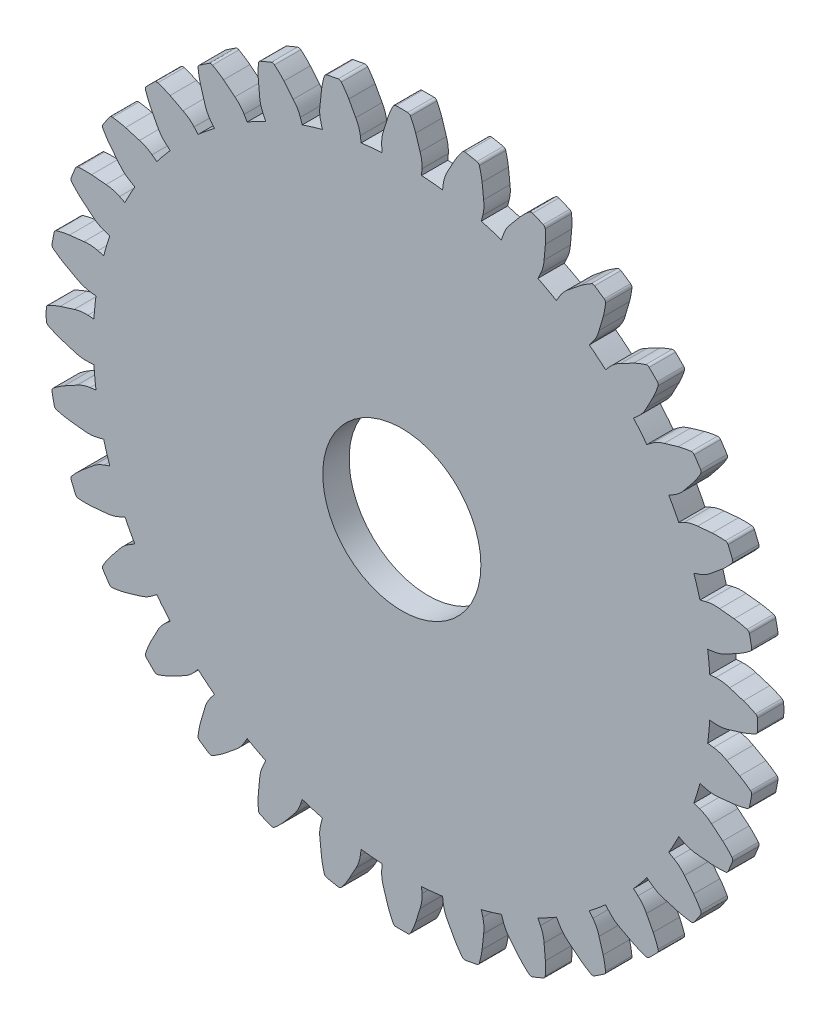
from build123d import *

# Parameters (mm, degrees)
MODEL_R             = 6
BOSS_EXTRUDE1_DEPTH = 2


with BuildPart() as part:
    # Model → Boss-Extrude1 (new body)
    with BuildSketch(Plane.XY):
        with BuildLine():
            Line((51.586845326, 30.54868928), (52.03848659, 30.577630118))
            ThreePointArc((52.03848659, 30.577630118), (52.570679137, 30.558733236), (53.08864278, 30.435041426))
            ThreePointArc((53.08864278, 30.435041426), (53.617059195, 30.27036576), (54.145449742, 30.105607112))
            ThreePointArc((54.145449742, 30.105607112), (54.613471462, 29.924451771), (55.067641968, 29.710931892))
            ThreePointArc((55.067641968, 29.710931892), (55.165460247, 29.620801386), (55.203028673, 29.493206177))
            ThreePointArc((55.203028673, 29.493206177), (55.205742279, 29.272262721), (55.206646834, 29.051304453))
            ThreePointArc((55.206646834, 29.051304453), (55.205742279, 28.830346185), (55.203028673, 28.609402728))
            ThreePointArc((55.203028673, 28.609402728), (55.165460247, 28.48180752), (55.067641968, 28.391677014))
            ThreePointArc((55.067641968, 28.391677014), (54.613471462, 28.178157135), (54.145449742, 27.997001794))
            ThreePointArc((54.145449742, 27.997001794), (53.617059195, 27.832243146), (53.08864278, 27.667567479))
            ThreePointArc((53.08864278, 27.667567479), (52.570679137, 27.54387567), (52.03848659, 27.524978787))
            Line((52.03848659, 27.524978787), (51.586845326, 27.553919625))
            ThreePointArc((51.586845326, 27.553919625), (51.557841022, 27.154768738), (51.522019199, 26.756171851))
            ThreePointArc((51.522019199, 26.756171851), (51.479390321, 26.358245401), (51.42996684, 25.961105627))
            Line((51.42996684, 25.961105627), (51.878576021, 25.901379535))
            ThreePointArc((51.878576021, 25.901379535), (52.396856039, 25.779020136), (52.880736081, 25.556655336))
            ThreePointArc((52.880736081, 25.556655336), (53.366872493, 25.292054937), (53.852967347, 25.027378199))
            ThreePointArc((53.852967347, 25.027378199), (54.276654506, 24.758397199), (54.680442592, 24.460375774))
            ThreePointArc((54.680442592, 24.460375774), (54.758797731, 24.352893701), (54.7707517, 24.220420962))
            ThreePointArc((54.7707517, 24.220420962), (54.730309234, 24.003193474), (54.688089589, 23.786304387))
            ThreePointArc((54.688089589, 23.786304387), (54.644095595, 23.56976824), (54.5983302, 23.353599549))
            ThreePointArc((54.5983302, 23.353599549), (54.536591051, 23.235785283), (54.423068733, 23.166470009))
            ThreePointArc((54.423068733, 23.166470009), (53.935969324, 23.045657125), (53.441598856, 22.959289141))
            ThreePointArc((53.441598856, 22.959289141), (52.891218368, 22.900780166), (52.340828698, 22.842357625))
            ThreePointArc((52.340828698, 22.842357625), (51.808686506, 22.822092213), (51.28303329, 22.907384044))
            Line((51.28303329, 22.907384044), (50.845716264, 23.023879631))
            ThreePointArc((50.845716264, 23.023879631), (50.739398794, 22.638056775), (50.626502883, 22.254107307))
            ThreePointArc((50.626502883, 22.254107307), (50.507061507, 21.872143384), (50.381109558, 21.492276582))
            Line((50.381109558, 21.492276582), (50.809446857, 21.346178801))
            ThreePointArc((50.809446857, 21.346178801), (51.293897135, 21.125059087), (51.725098337, 20.812566651))
            ThreePointArc((51.725098337, 20.812566651), (52.150272798, 20.458209966), (52.575391605, 20.103786515))
            ThreePointArc((52.575391605, 20.103786515), (52.938462145, 19.757316645), (53.27635046, 19.386246471))
            ThreePointArc((53.27635046, 19.386246471), (53.332231314, 19.265543306), (53.318111442, 19.13328389))
            ThreePointArc((53.318111442, 19.13328389), (53.236067086, 18.928120302), (53.152345718, 18.723635322))
            ThreePointArc((53.152345718, 18.723635322), (53.066952949, 18.519842659), (52.979894504, 18.316755974))
            ThreePointArc((52.979894504, 18.316755974), (52.896357232, 18.213250186), (52.771493475, 18.167413891))
            ThreePointArc((52.771493475, 18.167413891), (52.270184119, 18.143950773), (51.768463284, 18.15568922))
            ThreePointArc((51.768463284, 18.15568922), (51.217243668, 18.205678385), (50.666031908, 18.255754115))
            ThreePointArc((50.666031908, 18.255754115), (50.140161094, 18.339693888), (49.641247768, 18.525896716))
            Line((49.641247768, 18.525896716), (49.235060827, 18.725470193))
            ThreePointArc((49.235060827, 18.725470193), (49.055515913, 18.367802324), (48.869884439, 18.013255237))
            ThreePointArc((48.869884439, 18.013255237), (48.678220632, 17.6619325), (48.480580477, 17.313936738))
            Line((48.480580477, 17.313936738), (48.872185132, 17.087081723))
            ThreePointArc((48.872185132, 17.087081723), (49.304188517, 16.775699202), (49.666140059, 16.38508804))
            ThreePointArc((49.666140059, 16.38508804), (50.014013352, 15.954592796), (50.361819035, 15.524042928))
            ThreePointArc((50.361819035, 15.524042928), (50.650320358, 15.113398831), (50.909324044, 14.683539926))
            ThreePointArc((50.909324044, 14.683539926), (50.940583144, 14.554254225), (50.900932049, 14.427290787))
            ThreePointArc((50.900932049, 14.427290787), (50.780438722, 14.242075419), (50.658432996, 14.057852789))
            ThreePointArc((50.658432996, 14.057852789), (50.534923049, 13.874635248), (50.409917161, 13.692435076))
            ThreePointArc((50.409917161, 13.692435076), (50.307792057, 13.607215437), (50.176385304, 13.586619584))
            ThreePointArc((50.176385304, 13.586619584), (49.68013104, 13.661407907), (49.190340687, 13.770801682))
            ThreePointArc((49.190340687, 13.770801682), (48.659465004, 13.927367932), (48.128613914, 14.08401755))
            ThreePointArc((48.128613914, 14.08401755), (47.629223397, 14.268936751), (47.176222921, 14.548894905))
            Line((47.176222921, 14.548894905), (46.816775602, 14.823876774))
            ThreePointArc((46.816775602, 14.823876774), (46.570903053, 14.508108868), (46.319669731, 14.196589208))
            ThreePointArc((46.319669731, 14.196589208), (46.063149024, 13.889408793), (45.801415864, 13.586657354))
            Line((45.801415864, 13.586657354), (46.141238727, 13.287763016))
            ThreePointArc((46.141238727, 13.287763016), (46.504193572, 12.898083943), (46.78298586, 12.444365022))
            ThreePointArc((46.78298586, 12.444365022), (47.040189409, 11.954274911), (47.297315991, 11.464144415))
            ThreePointArc((47.297315991, 11.464144415), (47.500161153, 11.005106913), (47.670326843, 10.532978514))
            ThreePointArc((47.670326843, 10.532978514), (47.675762919, 10.400078653), (47.612104371, 10.283290327))
            ThreePointArc((47.612104371, 10.283290327), (47.457792564, 10.125140902), (47.302191091, 9.968260195))
            ThreePointArc((47.302191091, 9.968260195), (47.145310384, 9.812658723), (46.987160959, 9.658346916))
            ThreePointArc((46.987160959, 9.658346916), (46.870372633, 9.594688367), (46.737472773, 9.600124443))
            ThreePointArc((46.737472773, 9.600124443), (46.265344374, 9.770290134), (45.806306872, 9.973135296))
            ThreePointArc((45.806306872, 9.973135296), (45.316176376, 10.230261878), (44.826086265, 10.487465427))
            ThreePointArc((44.826086265, 10.487465427), (44.372367343, 10.766257714), (43.982688271, 11.129212559))
            Line((43.982688271, 11.129212559), (43.683793933, 11.469035423))
            ThreePointArc((43.683793933, 11.469035423), (43.381042494, 11.207302263), (43.073862078, 10.950781556))
            ThreePointArc((43.073862078, 10.950781556), (42.762342418, 10.699548234), (42.446574512, 10.453675685))
            Line((42.446574512, 10.453675685), (42.721556382, 10.094228366))
            ThreePointArc((42.721556382, 10.094228366), (43.001514536, 9.64122789), (43.186433737, 9.141837373))
            ThreePointArc((43.186433737, 9.141837373), (43.343083355, 8.610986283), (43.499649605, 8.080110599))
            ThreePointArc((43.499649605, 8.080110599), (43.60904338, 7.590320246), (43.683831703, 7.094065983))
            ThreePointArc((43.683831703, 7.094065983), (43.66323585, 6.96265923), (43.578016211, 6.860534125))
            ThreePointArc((43.578016211, 6.860534125), (43.395816039, 6.735528238), (43.212598498, 6.612018291))
            ThreePointArc((43.212598498, 6.612018291), (43.028375868, 6.490012565), (42.8431605, 6.369519238))
            ThreePointArc((42.8431605, 6.369519238), (42.716197062, 6.329868142), (42.586911361, 6.361127242))
            ThreePointArc((42.586911361, 6.361127242), (42.157052456, 6.620130929), (41.746408359, 6.908632251))
            ThreePointArc((41.746408359, 6.908632251), (41.31585849, 7.256437934), (40.885363247, 7.604311227))
            ThreePointArc((40.885363247, 7.604311227), (40.494752084, 7.966262769), (40.183369563, 8.398266155))
            Line((40.183369563, 8.398266155), (39.956514548, 8.78987081))
            ThreePointArc((39.956514548, 8.78987081), (39.608518787, 8.592230655), (39.25719605, 8.400566847))
            ThreePointArc((39.25719605, 8.400566847), (38.902648963, 8.214935374), (38.544981094, 8.035390459))
            Line((38.544981094, 8.035390459), (38.744554571, 7.629203519))
            ThreePointArc((38.744554571, 7.629203519), (38.930757398, 7.130290193), (39.014697172, 6.604419378))
            ThreePointArc((39.014697172, 6.604419378), (39.064772901, 6.053207619), (39.114762067, 5.501988003))
            ThreePointArc((39.114762067, 5.501988003), (39.126500513, 5.000267167), (39.103037396, 4.498957812))
            ThreePointArc((39.103037396, 4.498957812), (39.057201101, 4.374094055), (38.953695313, 4.290556782))
            ThreePointArc((38.953695313, 4.290556782), (38.750608628, 4.203498338), (38.546815965, 4.118105569))
            ThreePointArc((38.546815965, 4.118105569), (38.342330985, 4.034384201), (38.137167396, 3.952339845))
            ThreePointArc((38.137167396, 3.952339845), (38.004907981, 3.938219973), (37.884204816, 3.994100827))
            ThreePointArc((37.884204816, 3.994100827), (37.513134641, 4.331989142), (37.166664772, 4.695059682))
            ThreePointArc((37.166664772, 4.695059682), (36.812241321, 5.120178489), (36.457884636, 5.545352949))
            ThreePointArc((36.457884636, 5.545352949), (36.1453922, 5.976554152), (35.924272486, 6.461004429))
            Line((35.924272486, 6.461004429), (35.778174705, 6.889341729))
            ThreePointArc((35.778174705, 6.889341729), (35.398307903, 6.763389779), (35.01634398, 6.643948404))
            ThreePointArc((35.01634398, 6.643948404), (34.632394512, 6.531052492), (34.246571656, 6.424735023))
            Line((34.246571656, 6.424735023), (34.363067243, 5.987417997))
            ThreePointArc((34.363067243, 5.987417997), (34.448359074, 5.461764781), (34.428093662, 4.929622589))
            ThreePointArc((34.428093662, 4.929622589), (34.369671121, 4.379232919), (34.311162146, 3.828852431))
            ThreePointArc((34.311162146, 3.828852431), (34.224794162, 3.334481963), (34.103981278, 2.847382554))
            ThreePointArc((34.103981278, 2.847382554), (34.034666004, 2.733860236), (33.916851738, 2.672121086))
            ThreePointArc((33.916851738, 2.672121086), (33.700683046, 2.626355692), (33.484146899, 2.582361698))
            ThreePointArc((33.484146899, 2.582361698), (33.267257812, 2.540142053), (33.050030325, 2.499699587))
            ThreePointArc((33.050030325, 2.499699587), (32.917557586, 2.511653556), (32.810075513, 2.590008695))
            ThreePointArc((32.810075513, 2.590008695), (32.512054088, 2.99379678), (32.243073088, 3.41748394))
            ThreePointArc((32.243073088, 3.41748394), (31.978396349, 3.903578793), (31.713795951, 4.389715206))
            ThreePointArc((31.713795951, 4.389715206), (31.491431151, 4.873595248), (31.369071751, 5.391875265))
            Line((31.369071751, 5.391875265), (31.30934566, 5.840484447))
            ThreePointArc((31.30934566, 5.840484447), (30.912205885, 5.791060966), (30.514279435, 5.748432087))
            ThreePointArc((30.514279435, 5.748432087), (30.115682549, 5.712610264), (29.716531662, 5.683605961))
            Line((29.716531662, 5.683605961), (29.7454725, 5.231964697))
            ThreePointArc((29.7454725, 5.231964697), (29.726575617, 4.699772149), (29.602883807, 4.181808506))
            ThreePointArc((29.602883807, 4.181808506), (29.438208141, 3.653392092), (29.273449493, 3.125001545))
            ThreePointArc((29.273449493, 3.125001545), (29.092294152, 2.656979825), (28.878774273, 2.202809318))
            ThreePointArc((28.878774273, 2.202809318), (28.788643767, 2.10499104), (28.661048558, 2.067422613))
            ThreePointArc((28.661048558, 2.067422613), (28.440105102, 2.064709008), (28.219146834, 2.063804453))
            ThreePointArc((28.219146834, 2.063804453), (27.998188566, 2.064709008), (27.77724511, 2.067422613))
            ThreePointArc((27.77724511, 2.067422613), (27.649649901, 2.10499104), (27.559519395, 2.202809318))
            ThreePointArc((27.559519395, 2.202809318), (27.345999516, 2.656979825), (27.164844175, 3.125001545))
            ThreePointArc((27.164844175, 3.125001545), (27.000085527, 3.653392092), (26.835409861, 4.181808506))
            ThreePointArc((26.835409861, 4.181808506), (26.711718051, 4.699772149), (26.692821168, 5.231964697))
            Line((26.692821168, 5.231964697), (26.721762006, 5.683605961))
            ThreePointArc((26.721762006, 5.683605961), (26.322611119, 5.712610264), (25.924014232, 5.748432087))
            ThreePointArc((25.924014232, 5.748432087), (25.526087783, 5.791060966), (25.128948008, 5.840484447))
            Line((25.128948008, 5.840484447), (25.069221917, 5.391875265))
            ThreePointArc((25.069221917, 5.391875265), (24.946862517, 4.873595248), (24.724497717, 4.389715206))
            ThreePointArc((24.724497717, 4.389715206), (24.459897319, 3.903578793), (24.19522058, 3.41748394))
            ThreePointArc((24.19522058, 3.41748394), (23.92623958, 2.99379678), (23.628218155, 2.590008695))
            ThreePointArc((23.628218155, 2.590008695), (23.520736082, 2.511653556), (23.388263343, 2.499699587))
            ThreePointArc((23.388263343, 2.499699587), (23.171035856, 2.540142053), (22.954146769, 2.582361698))
            ThreePointArc((22.954146769, 2.582361698), (22.737610622, 2.626355692), (22.52144193, 2.672121086))
            ThreePointArc((22.52144193, 2.672121086), (22.403627664, 2.733860236), (22.33431239, 2.847382554))
            ThreePointArc((22.33431239, 2.847382554), (22.213499506, 3.334481963), (22.127131522, 3.828852431))
            ThreePointArc((22.127131522, 3.828852431), (22.068622547, 4.379232919), (22.010200006, 4.929622589))
            ThreePointArc((22.010200006, 4.929622589), (21.989934594, 5.461764781), (22.075226425, 5.987417997))
            Line((22.075226425, 5.987417997), (22.191722012, 6.424735023))
            ThreePointArc((22.191722012, 6.424735023), (21.805899156, 6.531052492), (21.421949688, 6.643948404))
            ThreePointArc((21.421949688, 6.643948404), (21.039985765, 6.763389779), (20.660118963, 6.889341729))
            Line((20.660118963, 6.889341729), (20.514021182, 6.461004429))
            ThreePointArc((20.514021182, 6.461004429), (20.292901468, 5.976554152), (19.980409032, 5.545352949))
            ThreePointArc((19.980409032, 5.545352949), (19.626052347, 5.120178489), (19.271628896, 4.695059682))
            ThreePointArc((19.271628896, 4.695059682), (18.925159026, 4.331989142), (18.554088852, 3.994100827))
            ThreePointArc((18.554088852, 3.994100827), (18.433385687, 3.938219973), (18.301126272, 3.952339845))
            ThreePointArc((18.301126272, 3.952339845), (18.095962683, 4.034384201), (17.891477703, 4.118105569))
            ThreePointArc((17.891477703, 4.118105569), (17.68768504, 4.203498338), (17.484598355, 4.290556782))
            ThreePointArc((17.484598355, 4.290556782), (17.381092567, 4.374094055), (17.335256272, 4.498957812))
            ThreePointArc((17.335256272, 4.498957812), (17.311793154, 5.000267167), (17.323531601, 5.501988003))
            ThreePointArc((17.323531601, 5.501988003), (17.373520767, 6.053207619), (17.423596496, 6.604419378))
            ThreePointArc((17.423596496, 6.604419378), (17.50753627, 7.130290193), (17.693739097, 7.629203519))
            Line((17.693739097, 7.629203519), (17.893312574, 8.035390459))
            ThreePointArc((17.893312574, 8.035390459), (17.535644705, 8.214935374), (17.181097618, 8.400566847))
            ThreePointArc((17.181097618, 8.400566847), (16.829774881, 8.592230655), (16.48177912, 8.78987081))
            Line((16.48177912, 8.78987081), (16.254924105, 8.398266155))
            ThreePointArc((16.254924105, 8.398266155), (15.943541583, 7.966262769), (15.552930421, 7.604311227))
            ThreePointArc((15.552930421, 7.604311227), (15.122435178, 7.256437934), (14.691885309, 6.908632251))
            ThreePointArc((14.691885309, 6.908632251), (14.281241212, 6.620130929), (13.851382307, 6.361127242))
            ThreePointArc((13.851382307, 6.361127242), (13.722096606, 6.329868142), (13.595133168, 6.369519238))
            ThreePointArc((13.595133168, 6.369519238), (13.4099178, 6.490012565), (13.22569517, 6.612018291))
            ThreePointArc((13.22569517, 6.612018291), (13.042477629, 6.735528238), (12.860277457, 6.860534125))
            ThreePointArc((12.860277457, 6.860534125), (12.775057818, 6.96265923), (12.754461965, 7.094065983))
            ThreePointArc((12.754461965, 7.094065983), (12.829250288, 7.590320246), (12.938644063, 8.080110599))
            ThreePointArc((12.938644063, 8.080110599), (13.095210313, 8.610986283), (13.251859931, 9.141837373))
            ThreePointArc((13.251859931, 9.141837373), (13.436779132, 9.64122789), (13.716737286, 10.094228366))
            Line((13.716737286, 10.094228366), (13.991719155, 10.453675685))
            ThreePointArc((13.991719155, 10.453675685), (13.675951249, 10.699548234), (13.364431589, 10.950781556))
            ThreePointArc((13.364431589, 10.950781556), (13.057251174, 11.207302263), (12.754499735, 11.469035423))
            Line((12.754499735, 11.469035423), (12.455605397, 11.129212559))
            ThreePointArc((12.455605397, 11.129212559), (12.065926325, 10.766257714), (11.612207403, 10.487465427))
            ThreePointArc((11.612207403, 10.487465427), (11.122117292, 10.230261878), (10.631986796, 9.973135296))
            ThreePointArc((10.631986796, 9.973135296), (10.172949294, 9.770290134), (9.700820895, 9.600124443))
            ThreePointArc((9.700820895, 9.600124443), (9.567921035, 9.594688367), (9.451132709, 9.658346916))
            ThreePointArc((9.451132709, 9.658346916), (9.292983284, 9.812658723), (9.136102577, 9.968260195))
            ThreePointArc((9.136102577, 9.968260195), (8.980501104, 10.125140902), (8.826189297, 10.283290327))
            ThreePointArc((8.826189297, 10.283290327), (8.762530748, 10.400078653), (8.767966825, 10.532978514))
            ThreePointArc((8.767966825, 10.532978514), (8.938132515, 11.005106913), (9.140977677, 11.464144415))
            ThreePointArc((9.140977677, 11.464144415), (9.398104259, 11.954274911), (9.655307808, 12.444365022))
            ThreePointArc((9.655307808, 12.444365022), (9.934100095, 12.898083943), (10.29705494, 13.287763016))
            Line((10.29705494, 13.287763016), (10.636877804, 13.586657354))
            ThreePointArc((10.636877804, 13.586657354), (10.375144644, 13.889408793), (10.118623937, 14.196589208))
            ThreePointArc((10.118623937, 14.196589208), (9.867390615, 14.508108868), (9.621518066, 14.823876774))
            Line((9.621518066, 14.823876774), (9.262070747, 14.548894905))
            ThreePointArc((9.262070747, 14.548894905), (8.809070271, 14.268936751), (8.309679754, 14.08401755))
            ThreePointArc((8.309679754, 14.08401755), (7.778828664, 13.927367932), (7.247952981, 13.770801682))
            ThreePointArc((7.247952981, 13.770801682), (6.758162628, 13.661407907), (6.261908364, 13.586619584))
            ThreePointArc((6.261908364, 13.586619584), (6.130501611, 13.607215437), (6.028376507, 13.692435076))
            ThreePointArc((6.028376507, 13.692435076), (5.903370619, 13.874635248), (5.779860672, 14.057852789))
            ThreePointArc((5.779860672, 14.057852789), (5.657854946, 14.242075419), (5.537361619, 14.427290787))
            ThreePointArc((5.537361619, 14.427290787), (5.497710524, 14.554254225), (5.528969624, 14.683539926))
            ThreePointArc((5.528969624, 14.683539926), (5.78797331, 15.113398831), (6.076474633, 15.524042928))
            ThreePointArc((6.076474633, 15.524042928), (6.424280316, 15.954592796), (6.772153608, 16.385088039))
            ThreePointArc((6.772153608, 16.385088039), (7.134105151, 16.775699202), (7.566108536, 17.087081723))
            Line((7.566108536, 17.087081723), (7.957713191, 17.313936738))
            ThreePointArc((7.957713191, 17.313936738), (7.760073036, 17.6619325), (7.568409228, 18.013255237))
            ThreePointArc((7.568409228, 18.013255237), (7.382777755, 18.367802324), (7.203232841, 18.725470193))
            Line((7.203232841, 18.725470193), (6.7970459, 18.525896716))
            ThreePointArc((6.7970459, 18.525896716), (6.298132574, 18.339693888), (5.77226176, 18.255754115))
            ThreePointArc((5.77226176, 18.255754115), (5.22105, 18.205678385), (4.669830384, 18.15568922))
            ThreePointArc((4.669830384, 18.15568922), (4.168109549, 18.143950773), (3.666800193, 18.167413891))
            ThreePointArc((3.666800193, 18.167413891), (3.541936436, 18.213250186), (3.458399164, 18.316755974))
            ThreePointArc((3.458399164, 18.316755974), (3.371340719, 18.519842659), (3.28594795, 18.723635322))
            ThreePointArc((3.28594795, 18.723635322), (3.202226582, 18.928120302), (3.120182226, 19.13328389))
            ThreePointArc((3.120182226, 19.13328389), (3.106062354, 19.265543306), (3.161943208, 19.386246471))
            ThreePointArc((3.161943208, 19.386246471), (3.499831523, 19.757316645), (3.862902063, 20.103786515))
            ThreePointArc((3.862902063, 20.103786515), (4.28802087, 20.458209966), (4.713195331, 20.812566651))
            ThreePointArc((4.713195331, 20.812566651), (5.144396533, 21.125059087), (5.628846811, 21.346178801))
            Line((5.628846811, 21.346178801), (6.05718411, 21.492276582))
            ThreePointArc((6.05718411, 21.492276582), (5.931232161, 21.872143384), (5.811790785, 22.254107307))
            ThreePointArc((5.811790785, 22.254107307), (5.698894874, 22.638056775), (5.592577404, 23.023879631))
            Line((5.592577404, 23.023879631), (5.155260378, 22.907384044))
            ThreePointArc((5.155260378, 22.907384044), (4.629607162, 22.822092213), (4.09746497, 22.842357625))
            ThreePointArc((4.09746497, 22.842357625), (3.5470753, 22.900780166), (2.996694812, 22.959289141))
            ThreePointArc((2.996694812, 22.959289141), (2.502324344, 23.045657125), (2.015224935, 23.166470009))
            ThreePointArc((2.015224935, 23.166470009), (1.901702617, 23.235785283), (1.839963468, 23.353599549))
            ThreePointArc((1.839963468, 23.353599549), (1.794198073, 23.56976824), (1.750204079, 23.786304387))
            ThreePointArc((1.750204079, 23.786304387), (1.707984434, 24.003193474), (1.667541968, 24.220420962))
            ThreePointArc((1.667541968, 24.220420962), (1.679495937, 24.352893701), (1.757851076, 24.460375774))
            ThreePointArc((1.757851076, 24.460375774), (2.161639161, 24.758397199), (2.585326321, 25.027378199))
            ThreePointArc((2.585326321, 25.027378199), (3.071421174, 25.292054937), (3.557557587, 25.556655336))
            ThreePointArc((3.557557587, 25.556655336), (4.041437629, 25.779020136), (4.559717647, 25.901379535))
            Line((4.559717647, 25.901379535), (5.008326828, 25.961105627))
            ThreePointArc((5.008326828, 25.961105627), (4.958903347, 26.358245401), (4.916274468, 26.756171851))
            ThreePointArc((4.916274468, 26.756171851), (4.880452646, 27.154768738), (4.851448342, 27.553919625))
            Line((4.851448342, 27.553919625), (4.399807078, 27.524978787))
            ThreePointArc((4.399807078, 27.524978787), (3.867614531, 27.54387567), (3.349650887, 27.667567479))
            ThreePointArc((3.349650887, 27.667567479), (2.821234473, 27.832243146), (2.292843926, 27.997001794))
            ThreePointArc((2.292843926, 27.997001794), (1.824822206, 28.178157135), (1.3706517, 28.391677014))
            ThreePointArc((1.3706517, 28.391677014), (1.272833421, 28.48180752), (1.235264995, 28.609402728))
            ThreePointArc((1.235264995, 28.609402728), (1.232551389, 28.830346185), (1.231646834, 29.051304453))
            ThreePointArc((1.231646834, 29.051304453), (1.232551389, 29.272262721), (1.235264995, 29.493206177))
            ThreePointArc((1.235264995, 29.493206177), (1.272833421, 29.620801386), (1.3706517, 29.710931892))
            ThreePointArc((1.3706517, 29.710931892), (1.824822206, 29.924451771), (2.292843926, 30.105607112))
            ThreePointArc((2.292843926, 30.105607112), (2.821234473, 30.27036576), (3.349650887, 30.435041426))
            ThreePointArc((3.349650887, 30.435041426), (3.867614531, 30.558733236), (4.399807078, 30.577630118))
            Line((4.399807078, 30.577630118), (4.851448342, 30.54868928))
            ThreePointArc((4.851448342, 30.54868928), (4.880452646, 30.947840168), (4.916274468, 31.346437054))
            ThreePointArc((4.916274468, 31.346437054), (4.958903347, 31.744363504), (5.008326828, 32.141503278))
            Line((5.008326828, 32.141503278), (4.559717647, 32.20122937))
            ThreePointArc((4.559717647, 32.20122937), (4.041437629, 32.32358877), (3.557557587, 32.54595357))
            ThreePointArc((3.557557587, 32.54595357), (3.071421174, 32.810553968), (2.585326321, 33.075230707))
            ThreePointArc((2.585326321, 33.075230707), (2.161639161, 33.344211707), (1.757851076, 33.642233131))
            ThreePointArc((1.757851076, 33.642233131), (1.679495937, 33.749715205), (1.667541968, 33.882187943))
            ThreePointArc((1.667541968, 33.882187943), (1.707984434, 34.099415431), (1.750204079, 34.316304518))
            ThreePointArc((1.750204079, 34.316304518), (1.794198073, 34.532840665), (1.839963468, 34.749009357))
            ThreePointArc((1.839963468, 34.749009357), (1.901702617, 34.866823623), (2.015224935, 34.936138897))
            ThreePointArc((2.015224935, 34.936138897), (2.502324344, 35.056951781), (2.996694812, 35.143319765))
            ThreePointArc((2.996694812, 35.143319765), (3.5470753, 35.201828739), (4.09746497, 35.260251281))
            ThreePointArc((4.09746497, 35.260251281), (4.629607162, 35.280516693), (5.155260378, 35.195224862))
            Line((5.155260378, 35.195224862), (5.592577404, 35.078729274))
            ThreePointArc((5.592577404, 35.078729274), (5.698894874, 35.464552131), (5.811790785, 35.848501599))
            ThreePointArc((5.811790785, 35.848501599), (5.931232161, 36.230465522), (6.05718411, 36.610332324))
            Line((6.05718411, 36.610332324), (5.628846811, 36.756430105))
            ThreePointArc((5.628846811, 36.756430105), (5.144396533, 36.977549819), (4.713195331, 37.290042255))
            ThreePointArc((4.713195331, 37.290042255), (4.28802087, 37.64439894), (3.862902063, 37.99882239))
            ThreePointArc((3.862902063, 37.99882239), (3.499831523, 38.34529226), (3.161943208, 38.716362435))
            ThreePointArc((3.161943208, 38.716362435), (3.106062354, 38.837065599), (3.120182226, 38.969325015))
            ThreePointArc((3.120182226, 38.969325015), (3.202226582, 39.174488604), (3.28594795, 39.378973584))
            ThreePointArc((3.28594795, 39.378973584), (3.371340719, 39.582766247), (3.458399164, 39.785852932))
            ThreePointArc((3.458399164, 39.785852932), (3.541936436, 39.889358719), (3.666800193, 39.935195015))
            ThreePointArc((3.666800193, 39.935195015), (4.168109549, 39.958658132), (4.669830384, 39.946919686))
            ThreePointArc((4.669830384, 39.946919686), (5.22105, 39.89693052), (5.77226176, 39.846854791))
            ThreePointArc((5.77226176, 39.846854791), (6.298132574, 39.762915017), (6.7970459, 39.57671219))
            Line((6.7970459, 39.57671219), (7.203232841, 39.377138713))
            ThreePointArc((7.203232841, 39.377138713), (7.382777755, 39.734806582), (7.568409228, 40.089353669))
            ThreePointArc((7.568409228, 40.089353669), (7.760073036, 40.440676406), (7.957713191, 40.788672167))
            Line((7.957713191, 40.788672167), (7.566108536, 41.015527182))
            ThreePointArc((7.566108536, 41.015527182), (7.134105151, 41.326909703), (6.772153608, 41.717520866))
            ThreePointArc((6.772153608, 41.717520866), (6.424280316, 42.148016109), (6.076474633, 42.578565977))
            ThreePointArc((6.076474633, 42.578565977), (5.78797331, 42.989210075), (5.528969624, 43.41906898))
            ThreePointArc((5.528969624, 43.41906898), (5.497710524, 43.548354681), (5.537361619, 43.675318119))
            ThreePointArc((5.537361619, 43.675318119), (5.657854946, 43.860533487), (5.779860672, 44.044756116))
            ThreePointArc((5.779860672, 44.044756116), (5.903370619, 44.227973658), (6.028376507, 44.410173829))
            ThreePointArc((6.028376507, 44.410173829), (6.130501611, 44.495393469), (6.261908364, 44.515989322))
            ThreePointArc((6.261908364, 44.515989322), (6.758162628, 44.441200999), (7.247952981, 44.331807224))
            ThreePointArc((7.247952981, 44.331807224), (7.778828664, 44.175240974), (8.309679754, 44.018591356))
            ThreePointArc((8.309679754, 44.018591356), (8.809070271, 43.833672155), (9.262070747, 43.553714001))
            Line((9.262070747, 43.553714001), (9.621518066, 43.278732131))
            ThreePointArc((9.621518066, 43.278732131), (9.867390615, 43.594500037), (10.118623937, 43.906019697))
            ThreePointArc((10.118623937, 43.906019697), (10.375144644, 44.213200112), (10.636877804, 44.515951552))
            Line((10.636877804, 44.515951552), (10.29705494, 44.814845889))
            ThreePointArc((10.29705494, 44.814845889), (9.934100095, 45.204524962), (9.655307808, 45.658243884))
            ThreePointArc((9.655307808, 45.658243884), (9.398104259, 46.148333994), (9.140977677, 46.63846449))
            ThreePointArc((9.140977677, 46.63846449), (8.938132515, 47.097501992), (8.767966825, 47.569630392))
            ThreePointArc((8.767966825, 47.569630392), (8.762530748, 47.702530252), (8.826189297, 47.819318578))
            ThreePointArc((8.826189297, 47.819318578), (8.980501104, 47.977468003), (9.136102577, 48.13434871))
            ThreePointArc((9.136102577, 48.13434871), (9.292983284, 48.289950183), (9.451132709, 48.44426199))
            ThreePointArc((9.451132709, 48.44426199), (9.567921035, 48.507920538), (9.700820895, 48.502484462))
            ThreePointArc((9.700820895, 48.502484462), (10.172949294, 48.332318771), (10.631986796, 48.12947361))
            ThreePointArc((10.631986796, 48.12947361), (11.122117292, 47.872347028), (11.612207403, 47.615143479))
            ThreePointArc((11.612207403, 47.615143479), (12.065926325, 47.336351191), (12.455605397, 46.973396346))
            Line((12.455605397, 46.973396346), (12.754499735, 46.633573483))
            ThreePointArc((12.754499735, 46.633573483), (13.057251174, 46.895306642), (13.364431589, 47.15182735))
            ThreePointArc((13.364431589, 47.15182735), (13.675951249, 47.403060672), (13.991719155, 47.648933221))
            Line((13.991719155, 47.648933221), (13.716737286, 48.008380539))
            ThreePointArc((13.716737286, 48.008380539), (13.436779132, 48.461381016), (13.251859931, 48.960771533))
            ThreePointArc((13.251859931, 48.960771533), (13.095210313, 49.491622623), (12.938644063, 50.022498306))
            ThreePointArc((12.938644063, 50.022498306), (12.829250288, 50.512288659), (12.754461965, 51.008542923))
            ThreePointArc((12.754461965, 51.008542923), (12.775057818, 51.139949676), (12.860277457, 51.24207478))
            ThreePointArc((12.860277457, 51.24207478), (13.042477629, 51.367080668), (13.22569517, 51.490590615))
            ThreePointArc((13.22569517, 51.490590615), (13.4099178, 51.612596341), (13.595133168, 51.733089668))
            ThreePointArc((13.595133168, 51.733089668), (13.722096606, 51.772740763), (13.851382307, 51.741481663))
            ThreePointArc((13.851382307, 51.741481663), (14.281241212, 51.482477977), (14.691885309, 51.193976654))
            ThreePointArc((14.691885309, 51.193976654), (15.122435178, 50.846170971), (15.552930421, 50.498297678))
            ThreePointArc((15.552930421, 50.498297678), (15.943541583, 50.136346136), (16.254924105, 49.704342751))
            Line((16.254924105, 49.704342751), (16.48177912, 49.312738096))
            ThreePointArc((16.48177912, 49.312738096), (16.829774881, 49.510378251), (17.181097618, 49.702042058))
            ThreePointArc((17.181097618, 49.702042058), (17.535644705, 49.887673532), (17.893312574, 50.067218446))
            Line((17.893312574, 50.067218446), (17.693739097, 50.473405387))
            ThreePointArc((17.693739097, 50.473405387), (17.50753627, 50.972318712), (17.423596496, 51.498189527))
            ThreePointArc((17.423596496, 51.498189527), (17.373520767, 52.049401286), (17.323531601, 52.600620903))
            ThreePointArc((17.323531601, 52.600620903), (17.311793154, 53.102341738), (17.335256272, 53.603651094))
            ThreePointArc((17.335256272, 53.603651094), (17.381092567, 53.728514851), (17.484598355, 53.812052123))
            ThreePointArc((17.484598355, 53.812052123), (17.68768504, 53.899110568), (17.891477703, 53.984503336))
            ThreePointArc((17.891477703, 53.984503336), (18.095962683, 54.068224705), (18.301126272, 54.15026906))
            ThreePointArc((18.301126272, 54.15026906), (18.433385687, 54.164388933), (18.554088852, 54.108508079))
            ThreePointArc((18.554088852, 54.108508079), (18.925159026, 53.770619763), (19.271628896, 53.407549224))
            ThreePointArc((19.271628896, 53.407549224), (19.626052347, 52.982430417), (19.980409032, 52.557255956))
            ThreePointArc((19.980409032, 52.557255956), (20.292901468, 52.126054754), (20.514021182, 51.641604476))
            Line((20.514021182, 51.641604476), (20.660118963, 51.213267177))
            ThreePointArc((20.660118963, 51.213267177), (21.039985765, 51.339219126), (21.421949688, 51.458660502))
            ThreePointArc((21.421949688, 51.458660502), (21.805899156, 51.571556413), (22.191722012, 51.677873883))
            Line((22.191722012, 51.677873883), (22.075226425, 52.115190909))
            ThreePointArc((22.075226425, 52.115190909), (21.989934594, 52.640844124), (22.010200006, 53.172986316))
            ThreePointArc((22.010200006, 53.172986316), (22.068622547, 53.723375986), (22.127131522, 54.273756475))
            ThreePointArc((22.127131522, 54.273756475), (22.213499506, 54.768126942), (22.33431239, 55.255226352))
            ThreePointArc((22.33431239, 55.255226352), (22.403627664, 55.36874867), (22.52144193, 55.430487819))
            ThreePointArc((22.52144193, 55.430487819), (22.737610622, 55.476253213), (22.954146769, 55.520247208))
            ThreePointArc((22.954146769, 55.520247208), (23.171035856, 55.562466853), (23.388263343, 55.602909319))
            ThreePointArc((23.388263343, 55.602909319), (23.520736082, 55.59095535), (23.628218155, 55.512600211))
            ThreePointArc((23.628218155, 55.512600211), (23.92623958, 55.108812125), (24.19522058, 54.685124965))
            ThreePointArc((24.19522058, 54.685124965), (24.459897319, 54.199030112), (24.724497717, 53.7128937))
            ThreePointArc((24.724497717, 53.7128937), (24.946862517, 53.229013658), (25.069221917, 52.71073364))
            Line((25.069221917, 52.71073364), (25.128948008, 52.262124459))
            ThreePointArc((25.128948008, 52.262124459), (25.526087783, 52.31154794), (25.924014232, 52.354176818))
            ThreePointArc((25.924014232, 52.354176818), (26.322611119, 52.389998641), (26.721762006, 52.419002945))
            Line((26.721762006, 52.419002945), (26.692821168, 52.870644209))
            ThreePointArc((26.692821168, 52.870644209), (26.711718051, 53.402836756), (26.835409861, 53.920800399))
            ThreePointArc((26.835409861, 53.920800399), (27.000085527, 54.449216814), (27.164844175, 54.977607361))
            ThreePointArc((27.164844175, 54.977607361), (27.345999516, 55.44562908), (27.559519395, 55.899799587))
            ThreePointArc((27.559519395, 55.899799587), (27.649649901, 55.997617866), (27.77724511, 56.035186292))
            ThreePointArc((27.77724511, 56.035186292), (27.998188566, 56.037899897), (28.219146834, 56.038804453))
            ThreePointArc((28.219146834, 56.038804453), (28.440105102, 56.037899897), (28.661048558, 56.035186292))
            ThreePointArc((28.661048558, 56.035186292), (28.788643767, 55.997617866), (28.878774273, 55.899799587))
            ThreePointArc((28.878774273, 55.899799587), (29.092294152, 55.44562908), (29.273449493, 54.977607361))
            ThreePointArc((29.273449493, 54.977607361), (29.438208141, 54.449216814), (29.602883807, 53.920800399))
            ThreePointArc((29.602883807, 53.920800399), (29.726575617, 53.402836756), (29.7454725, 52.870644209))
            Line((29.7454725, 52.870644209), (29.716531662, 52.419002945))
            ThreePointArc((29.716531662, 52.419002945), (30.115682549, 52.389998641), (30.514279435, 52.354176818))
            ThreePointArc((30.514279435, 52.354176818), (30.912205885, 52.31154794), (31.30934566, 52.262124459))
            Line((31.30934566, 52.262124459), (31.369071751, 52.71073364))
            ThreePointArc((31.369071751, 52.71073364), (31.491431151, 53.229013658), (31.713795951, 53.7128937))
            ThreePointArc((31.713795951, 53.7128937), (31.978396349, 54.199030112), (32.243073088, 54.685124965))
            ThreePointArc((32.243073088, 54.685124965), (32.512054088, 55.108812125), (32.810075513, 55.512600211))
            ThreePointArc((32.810075513, 55.512600211), (32.917557586, 55.59095535), (33.050030325, 55.602909319))
            ThreePointArc((33.050030325, 55.602909319), (33.267257812, 55.562466853), (33.484146899, 55.520247208))
            ThreePointArc((33.484146899, 55.520247208), (33.700683046, 55.476253213), (33.916851738, 55.430487819))
            ThreePointArc((33.916851738, 55.430487819), (34.034666004, 55.36874867), (34.103981278, 55.255226352))
            ThreePointArc((34.103981278, 55.255226352), (34.224794162, 54.768126942), (34.311162146, 54.273756475))
            ThreePointArc((34.311162146, 54.273756475), (34.369671121, 53.723375986), (34.428093662, 53.172986316))
            ThreePointArc((34.428093662, 53.172986316), (34.448359074, 52.640844124), (34.363067243, 52.115190909))
            Line((34.363067243, 52.115190909), (34.246571656, 51.677873883))
            ThreePointArc((34.246571656, 51.677873883), (34.632394512, 51.571556413), (35.01634398, 51.458660502))
            ThreePointArc((35.01634398, 51.458660502), (35.398307903, 51.339219126), (35.778174705, 51.213267177))
            Line((35.778174705, 51.213267177), (35.924272486, 51.641604476))
            ThreePointArc((35.924272486, 51.641604476), (36.1453922, 52.126054754), (36.457884636, 52.557255956))
            ThreePointArc((36.457884636, 52.557255956), (36.812241321, 52.982430417), (37.166664772, 53.407549224))
            ThreePointArc((37.166664772, 53.407549224), (37.513134641, 53.770619763), (37.884204816, 54.108508079))
            ThreePointArc((37.884204816, 54.108508079), (38.004907981, 54.164388933), (38.137167396, 54.15026906))
            ThreePointArc((38.137167396, 54.15026906), (38.342330985, 54.068224705), (38.546815965, 53.984503336))
            ThreePointArc((38.546815965, 53.984503336), (38.750608628, 53.899110568), (38.953695313, 53.812052123))
            ThreePointArc((38.953695313, 53.812052123), (39.057201101, 53.728514851), (39.103037396, 53.603651094))
            ThreePointArc((39.103037396, 53.603651094), (39.126500513, 53.102341738), (39.114762067, 52.600620903))
            ThreePointArc((39.114762067, 52.600620903), (39.064772901, 52.049401286), (39.014697172, 51.498189527))
            ThreePointArc((39.014697172, 51.498189527), (38.930757398, 50.972318712), (38.744554571, 50.473405387))
            Line((38.744554571, 50.473405387), (38.544981094, 50.067218446))
            ThreePointArc((38.544981094, 50.067218446), (38.902648963, 49.887673532), (39.25719605, 49.702042058))
            ThreePointArc((39.25719605, 49.702042058), (39.608518787, 49.510378251), (39.956514548, 49.312738096))
            Line((39.956514548, 49.312738096), (40.183369563, 49.704342751))
            ThreePointArc((40.183369563, 49.704342751), (40.494752084, 50.136346136), (40.885363247, 50.498297678))
            ThreePointArc((40.885363247, 50.498297678), (41.31585849, 50.846170971), (41.746408359, 51.193976654))
            ThreePointArc((41.746408359, 51.193976654), (42.157052456, 51.482477977), (42.586911361, 51.741481663))
            ThreePointArc((42.586911361, 51.741481663), (42.716197062, 51.772740763), (42.8431605, 51.733089668))
            ThreePointArc((42.8431605, 51.733089668), (43.028375868, 51.612596341), (43.212598498, 51.490590615))
            ThreePointArc((43.212598498, 51.490590615), (43.395816039, 51.367080668), (43.578016211, 51.24207478))
            ThreePointArc((43.578016211, 51.24207478), (43.66323585, 51.139949676), (43.683831703, 51.008542923))
            ThreePointArc((43.683831703, 51.008542923), (43.60904338, 50.512288659), (43.499649605, 50.022498306))
            ThreePointArc((43.499649605, 50.022498306), (43.343083355, 49.491622623), (43.186433737, 48.960771533))
            ThreePointArc((43.186433737, 48.960771533), (43.001514536, 48.461381016), (42.721556382, 48.008380539))
            Line((42.721556382, 48.008380539), (42.446574512, 47.648933221))
            ThreePointArc((42.446574512, 47.648933221), (42.762342418, 47.403060672), (43.073862078, 47.15182735))
            ThreePointArc((43.073862078, 47.15182735), (43.381042494, 46.895306642), (43.683793933, 46.633573483))
            Line((43.683793933, 46.633573483), (43.982688271, 46.973396346))
            ThreePointArc((43.982688271, 46.973396346), (44.372367343, 47.336351191), (44.826086265, 47.615143479))
            ThreePointArc((44.826086265, 47.615143479), (45.316176376, 47.872347028), (45.806306872, 48.12947361))
            ThreePointArc((45.806306872, 48.12947361), (46.265344374, 48.332318771), (46.737472773, 48.502484462))
            ThreePointArc((46.737472773, 48.502484462), (46.870372633, 48.507920538), (46.987160959, 48.44426199))
            ThreePointArc((46.987160959, 48.44426199), (47.145310384, 48.289950183), (47.302191091, 48.13434871))
            ThreePointArc((47.302191091, 48.13434871), (47.457792564, 47.977468003), (47.612104371, 47.819318578))
            ThreePointArc((47.612104371, 47.819318578), (47.675762919, 47.702530252), (47.670326843, 47.569630392))
            ThreePointArc((47.670326843, 47.569630392), (47.500161153, 47.097501992), (47.297315991, 46.63846449))
            ThreePointArc((47.297315991, 46.63846449), (47.040189409, 46.148333994), (46.78298586, 45.658243884))
            ThreePointArc((46.78298586, 45.658243884), (46.504193572, 45.204524962), (46.141238727, 44.814845889))
            Line((46.141238727, 44.814845889), (45.801415864, 44.515951552))
            ThreePointArc((45.801415864, 44.515951552), (46.063149024, 44.213200112), (46.319669731, 43.906019697))
            ThreePointArc((46.319669731, 43.906019697), (46.570903053, 43.594500037), (46.816775602, 43.278732131))
            Line((46.816775602, 43.278732131), (47.176222921, 43.553714001))
            ThreePointArc((47.176222921, 43.553714001), (47.629223397, 43.833672155), (48.128613914, 44.018591356))
            ThreePointArc((48.128613914, 44.018591356), (48.659465004, 44.175240974), (49.190340687, 44.331807224))
            ThreePointArc((49.190340687, 44.331807224), (49.68013104, 44.441200999), (50.176385304, 44.515989322))
            ThreePointArc((50.176385304, 44.515989322), (50.307792057, 44.495393469), (50.409917161, 44.410173829))
            ThreePointArc((50.409917161, 44.410173829), (50.534923049, 44.227973658), (50.658432996, 44.044756116))
            ThreePointArc((50.658432996, 44.044756116), (50.780438722, 43.860533487), (50.900932049, 43.675318119))
            ThreePointArc((50.900932049, 43.675318119), (50.940583144, 43.548354681), (50.909324044, 43.41906898))
            ThreePointArc((50.909324044, 43.41906898), (50.650320358, 42.989210075), (50.361819035, 42.578565977))
            ThreePointArc((50.361819035, 42.578565977), (50.014013352, 42.148016109), (49.66614006, 41.717520866))
            ThreePointArc((49.66614006, 41.717520866), (49.304188517, 41.326909703), (48.872185132, 41.015527182))
            Line((48.872185132, 41.015527182), (48.480580477, 40.788672167))
            ThreePointArc((48.480580477, 40.788672167), (48.678220632, 40.440676406), (48.869884439, 40.089353669))
            ThreePointArc((48.869884439, 40.089353669), (49.055515913, 39.734806582), (49.235060827, 39.377138713))
            Line((49.235060827, 39.377138713), (49.641247768, 39.57671219))
            ThreePointArc((49.641247768, 39.57671219), (50.140161094, 39.762915017), (50.666031908, 39.846854791))
            ThreePointArc((50.666031908, 39.846854791), (51.217243668, 39.89693052), (51.768463284, 39.946919686))
            ThreePointArc((51.768463284, 39.946919686), (52.270184119, 39.958658132), (52.771493475, 39.935195015))
            ThreePointArc((52.771493475, 39.935195015), (52.896357232, 39.889358719), (52.979894504, 39.785852932))
            ThreePointArc((52.979894504, 39.785852932), (53.066952949, 39.582766247), (53.152345718, 39.378973584))
            ThreePointArc((53.152345718, 39.378973584), (53.236067086, 39.174488604), (53.318111442, 38.969325015))
            ThreePointArc((53.318111442, 38.969325015), (53.332231314, 38.837065599), (53.27635046, 38.716362435))
            ThreePointArc((53.27635046, 38.716362435), (52.938462145, 38.34529226), (52.575391605, 37.99882239))
            ThreePointArc((52.575391605, 37.99882239), (52.150272798, 37.64439894), (51.725098337, 37.290042255))
            ThreePointArc((51.725098337, 37.290042255), (51.293897135, 36.977549819), (50.809446857, 36.756430105))
            Line((50.809446857, 36.756430105), (50.381109558, 36.610332324))
            ThreePointArc((50.381109558, 36.610332324), (50.507061507, 36.230465522), (50.626502883, 35.848501599))
            ThreePointArc((50.626502883, 35.848501599), (50.739398794, 35.464552131), (50.845716264, 35.078729274))
            Line((50.845716264, 35.078729274), (51.28303329, 35.195224862))
            ThreePointArc((51.28303329, 35.195224862), (51.808686506, 35.280516693), (52.340828698, 35.260251281))
            ThreePointArc((52.340828698, 35.260251281), (52.891218368, 35.201828739), (53.441598856, 35.143319765))
            ThreePointArc((53.441598856, 35.143319765), (53.935969324, 35.056951781), (54.423068733, 34.936138897))
            ThreePointArc((54.423068733, 34.936138897), (54.536591051, 34.866823623), (54.5983302, 34.749009357))
            ThreePointArc((54.5983302, 34.749009357), (54.644095595, 34.532840665), (54.688089589, 34.316304518))
            ThreePointArc((54.688089589, 34.316304518), (54.730309234, 34.099415431), (54.7707517, 33.882187943))
            ThreePointArc((54.7707517, 33.882187943), (54.758797731, 33.749715205), (54.680442592, 33.642233131))
            ThreePointArc((54.680442592, 33.642233131), (54.276654506, 33.344211707), (53.852967347, 33.075230707))
            ThreePointArc((53.852967347, 33.075230707), (53.366872493, 32.810553968), (52.880736081, 32.54595357))
            ThreePointArc((52.880736081, 32.54595357), (52.396856039, 32.32358877), (51.878576021, 32.20122937))
            Line((51.878576021, 32.20122937), (51.42996684, 32.141503278))
            ThreePointArc((51.42996684, 32.141503278), (51.479390321, 31.744363504), (51.522019199, 31.346437054))
            ThreePointArc((51.522019199, 31.346437054), (51.557841022, 30.947840168), (51.586845326, 30.54868928))
        make_face()
        with Locations((28.219146834, 29.051304453)):
            Circle(MODEL_R, mode=Mode.SUBTRACT)
    extrude(amount=BOSS_EXTRUDE1_DEPTH)


solid = part.part
